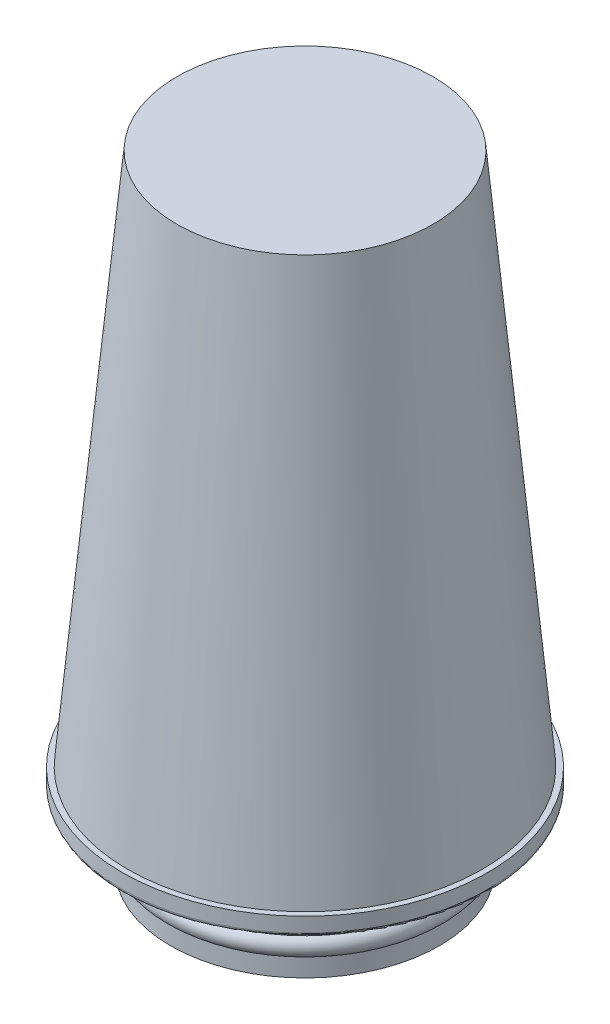
from build123d import *


with BuildPart() as part:
    # Sketch1 → Revolve1 (revolve)
    with BuildSketch(Plane.XY):
        with BuildLine():
            ThreePointArc((35.25, 18), (35.982233047, 19.767766953), (37.75, 20.5))
            Line((37.75, 20.5), (24.943493151, 159))
            Line((24.943493151, 159), (0, 159))
            Line((0, 159), (0, 170))
            Line((0, 170), (35, 170))
            Line((35, 170), (48.5, 24))
            Line((48.5, 24), (50, 24))
            Line((50, 24), (50, 20))
            ThreePointArc((50, 20), (49.707106781, 19.292893219), (49, 19))
            Line((49, 19), (37.75, 19))
            ThreePointArc((37.75, 19), (37.042893219, 18.707106781), (36.75, 18))
            Line((36.75, 18), (36.75, 10))
            ThreePointArc((36.75, 10), (38.25, 7.5), (36.75, 5))
            Line((36.75, 5), (36.75, 0))
            Line((36.75, 0), (35.25, 0))
            Line((35.25, 0), (35.25, 6.177124344))
            ThreePointArc((35.25, 6.177124344), (36.75, 7.5), (35.25, 8.822875656))
            Line((35.25, 8.822875656), (35.25, 18))
        make_face()
    revolve(axis=Axis((0, 170, 0), (0, -1, 0)))


solid = part.part
